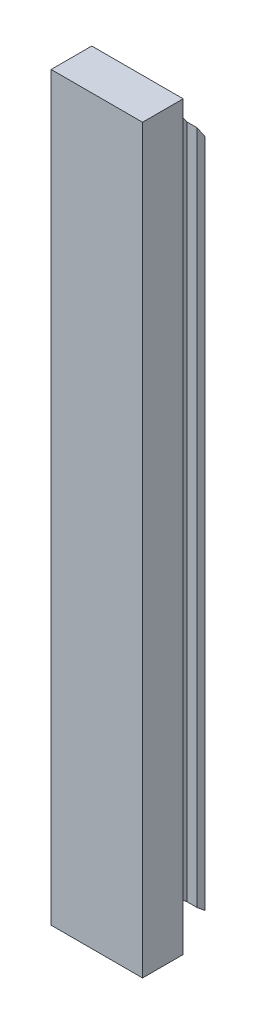
from build123d import *

# Parameters (mm, degrees)
SKETCH1_W             = 4
SKETCH1_H             = 66
BOSS_EXTRUDE1_DEPTH   = 1
SKETCH1_2_W           = 4
SKETCH1_2_H           = 66
BOSS_EXTRUDE2_DEPTH   = 1.36844839
SKETCH4_W             = 2
SKETCH4_H             = 66.494663906
BOSS_EXTRUDE3_DEPTH   = 5
SKETCH4_2_W           = 2
SKETCH4_2_H           = 66.494663906
BOSS_EXTRUDE4_DEPTH   = 6.842238407
F_3_0MM_DOWEL_HOLE1_D = 3
SKETCH9_W             = 9
SKETCH9_H             = 72.967983433
BOSS_EXTRUDE6_DEPTH   = 4


with BuildPart() as part:
    # Sketch1 → Boss-Extrude1 (new, along a direction that is not the sketch's normal)
    with BuildSketch(Plane.XY):
        Rectangle(SKETCH1_W, SKETCH1_H)
    extrude(amount=BOSS_EXTRUDE1_DEPTH, dir=(0, 0.6347305132022716, 0.7727335734973478))

    # Sketch1_2 → Boss-Extrude2 (add, along a direction that is not the sketch's normal)
    with BuildSketch(Plane.XY):
        Rectangle(SKETCH1_2_W, SKETCH1_2_H)
    extrude(amount=BOSS_EXTRUDE2_DEPTH, dir=(0, 0.8253106586930028, 0.5646789500660725))

    # Sketch4 → Boss-Extrude3 (add, along a direction that is not the sketch's normal)
    with BuildSketch(Plane.XY.offset(0.772733573)):
        with Locations((0, 0.882062466)):
            Rectangle(SKETCH4_W, SKETCH4_H)
    extrude(amount=BOSS_EXTRUDE3_DEPTH, dir=(0, 0.6347305132022716, 0.7727335734973478))

    # Sketch4_2 → Boss-Extrude4 (add, along a direction that is not the sketch's normal)
    with BuildSketch(Plane.XY.offset(0.772733573)):
        with Locations((0, 0.882062466)):
            Rectangle(SKETCH4_2_W, SKETCH4_2_H)
    extrude(amount=BOSS_EXTRUDE4_DEPTH, dir=(0, 0.8253106586930028, 0.5646789500660725))

    # Ø3.0mm Dowel Hole1 (through all)
    with Locations(Plane.ZY.offset(1)):
        with Locations((2.704567507, -14.191616921), (2.704567507, 15.808383079)):
            Hole(F_3_0MM_DOWEL_HOLE1_D / 2)

    # Sketch9 → Boss-Extrude6 (add)
    with BuildSketch(Plane.XY.offset(4.636401441)):
        with Locations((0, 3.292374795)):
            Rectangle(SKETCH9_W, SKETCH9_H)
    extrude(amount=BOSS_EXTRUDE6_DEPTH)


solid = part.part
